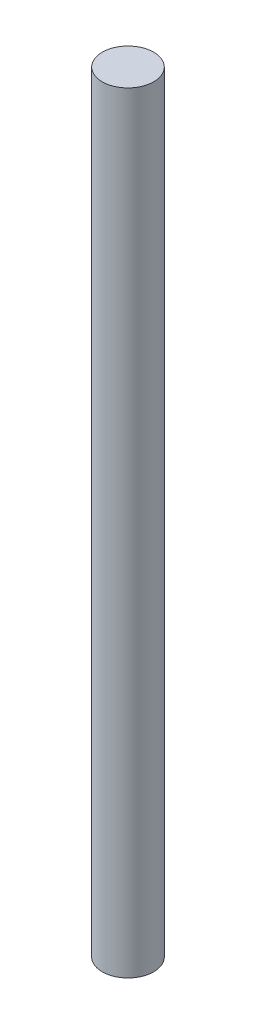
from build123d import *

# Parameters (mm, degrees)
SKETCH1_R           = 4
BOSS_EXTRUDE1_DEPTH = 120


with BuildPart() as part:
    # Sketch1 → Boss-Extrude1 (new body)
    with BuildSketch(Plane(origin=(0, 0, 0), x_dir=(1, 0, 0), z_dir=(0, 1, 0))):
        with Locations(Location((0, 0, 0), (0, 0, 270))):  # turned: the seam where the file's is
            Circle(SKETCH1_R)
    extrude(amount=BOSS_EXTRUDE1_DEPTH)


solid = part.part
